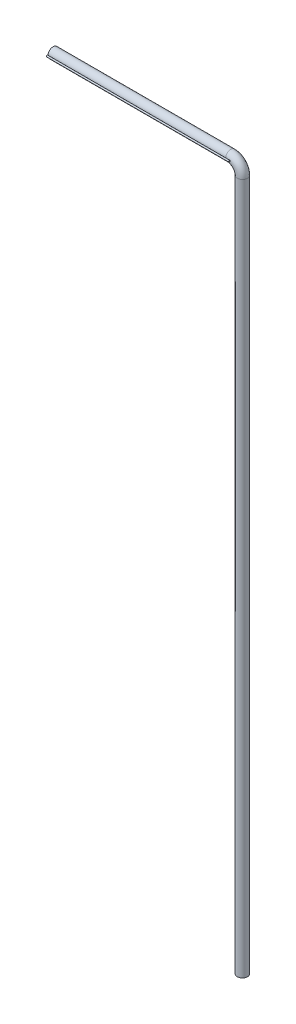
from build123d import *

# Parameters (mm, degrees)
CROQUIS1_R                = 52.8
SALIENTE_EXTRUIR2_DEPTH   = 10
CROQUIS3_R                = 52.8
CROQUIS3_R_2              = 50.8
CROQUIS4_R                = 13.7
SALIENTE_EXTRUIR3_DEPTH   = 1753
SALIENTE_EXTRUIR3_2_DEPTH = 1753
SALIENTE_EXTRUIR3_3_DEPTH = 1753
CROQUIS9_R                = 50.8
CORTAR_EXTRUIR1_DEPTH     = 100
CROQUIS11_R               = 52.8
CROQUIS11_R_2             = 50.8
SALIENTE_EXTRUIR4_DEPTH   = 1753
CROQUIS12_R               = 7.9375
SALIENTE_EXTRUIR5_DEPTH   = 1880


with BuildPart() as part:
    # Croquis1 → Saliente-Extruir2 (new body)
    with BuildSketch(Plane(origin=(0, 0, 0), x_dir=(1, 0, 0), z_dir=(0, 1, 0))):
        Circle(CROQUIS1_R)
    extrude(amount=SALIENTE_EXTRUIR2_DEPTH)

    # Barrer1: sweep along a curve in space
    with BuildLine() as barrer1_path:
        Line((0, 0, 0), (0, 7134, 0))
        ThreePointArc((0, 7134, 0), (-35.147186258, 7218.852813742, 0), (-120, 7254, 0))
        Line((-120, 7254, 0), (-200, 7254, 0))
    # Croquis3 → Barrer1 (sweep)
    with BuildSketch(Plane(origin=(0, 10, 0), x_dir=(1, 0, 0), z_dir=(0, 1, 0))):
        Circle(CROQUIS3_R)
        Circle(CROQUIS3_R_2, mode=Mode.SUBTRACT)
    sweep(path=barrer1_path.line)

    # Croquis9 → Cortar-Extruir1 (cut)
    with BuildSketch(Plane.XZ):
        Circle(CROQUIS9_R)
    extrude(amount=-CORTAR_EXTRUIR1_DEPTH, mode=Mode.SUBTRACT)

    # Croquis11 → Saliente-Extruir4 (add)
    with BuildSketch(Plane.ZY.offset(200)):
        with Locations((0, 7254)):
            Circle(CROQUIS11_R)
        with Locations((0, 7254)):
            Circle(CROQUIS11_R_2, mode=Mode.SUBTRACT)
    extrude(amount=SALIENTE_EXTRUIR4_DEPTH)


with BuildPart() as body_2:
    # Croquis4 → Saliente-Extruir3 (new body)
    with BuildSketch(Plane.ZY.offset(200)):
        with Locations((34.227483109, 7254)):
            Circle(CROQUIS4_R)
    extrude(amount=SALIENTE_EXTRUIR3_DEPTH)


with BuildPart() as body_3:
    # Croquis4 → Saliente-Extruir3 2 (new body)
    with BuildSketch(Plane.ZY.offset(200)):
        with Locations((0.367483109, 7254)):
            Circle(CROQUIS4_R)
    extrude(amount=SALIENTE_EXTRUIR3_2_DEPTH)


with BuildPart() as body_4:
    # Croquis4 → Saliente-Extruir3 3 (new body)
    with BuildSketch(Plane.ZY.offset(200)):
        with Locations((-33.492516891, 7254)):
            Circle(CROQUIS4_R)
    extrude(amount=SALIENTE_EXTRUIR3_3_DEPTH)


with BuildPart() as body_5:
    # Croquis12 → Saliente-Extruir5 (new body)
    with BuildSketch(Plane.ZY.offset(1953)):
        with Locations((61.700865987, 7254.167370401)):
            Circle(CROQUIS12_R)
    extrude(amount=-SALIENTE_EXTRUIR5_DEPTH)


solid = Compound([part.part, body_2.part, body_3.part, body_4.part, body_5.part])
